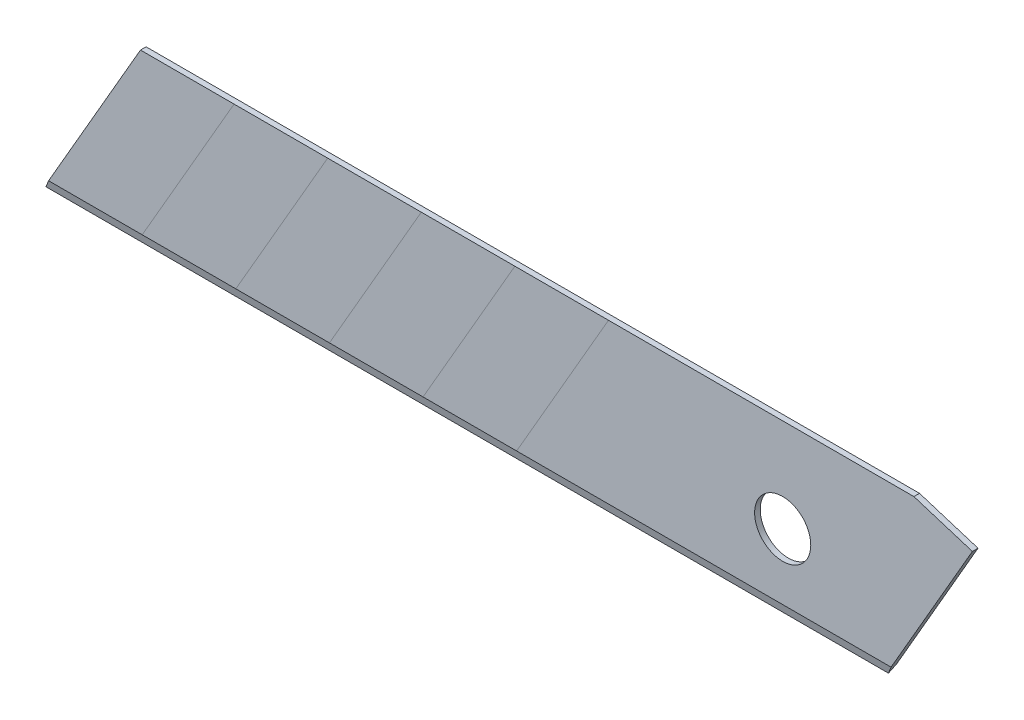
from build123d import *

# Parameters (mm, degrees)
SKETCH_1_R               = 1.5
EXTRUDE_1_DEPTH          = 0.15
CUT_EXTRUDE_1_DEPTH      = 13
CUT_EXTRUDE_1_DEPTH_BACK = 80.3
CUT_EXTRUDE_2_DEPTH      = 1.3


with BuildPart() as part:
    # 草图1 → 凸台-拉伸1 (new body, symmetric)
    with BuildSketch(Plane.XY):
        with BuildLine():
            Line((-74.5, -4), (5.5, -4))
            Line((5.5, -4), (10.132667282, 4.024015107))
            Line((10.132667282, 4.024015107), (7.009129504, 5))
            Line((7.009129504, 5), (-65.987869266, 5))
            ThreePointArc((-65.987869266, 5), (-67.885405091, 4.344282156), (-69.867332718, 4.024015107))
            Line((-69.867332718, 4.024015107), (-74.5, -4))
        make_face()
        Circle(SKETCH_1_R, mode=Mode.SUBTRACT)
    extrude(amount=EXTRUDE_1_DEPTH, both=True)

    # 草图3 → 切除-拉伸1 (cut, two sides)
    with BuildSketch(Plane(origin=(0, 0, 0), x_dir=(0, 0, -1), z_dir=(1, 0, 0))) as cut_extrude_1_sk:
        Polygon((0, -4), (-0.15, -3.5), (-0.747270974, -4.330450708), (0.60266722, -4.330450708), (0.15, -3.5), align=None)
    extrude(amount=CUT_EXTRUDE_1_DEPTH, mode=Mode.SUBTRACT)
    extrude(cut_extrude_1_sk.sketch, amount=-CUT_EXTRUDE_1_DEPTH_BACK, mode=Mode.SUBTRACT)

    # 草图7 → 切除-拉伸2 (cut, through all)
    with BuildSketch(Plane.XY.offset(0.15)):
        Polygon((-30.476363603, 11.629396709), (-39.5, -4), (-74.5, -4), (-62.953845349, 15.998526488), align=None)
    extrude(amount=-CUT_EXTRUDE_2_DEPTH, mode=Mode.SUBTRACT)


solid = part.part
